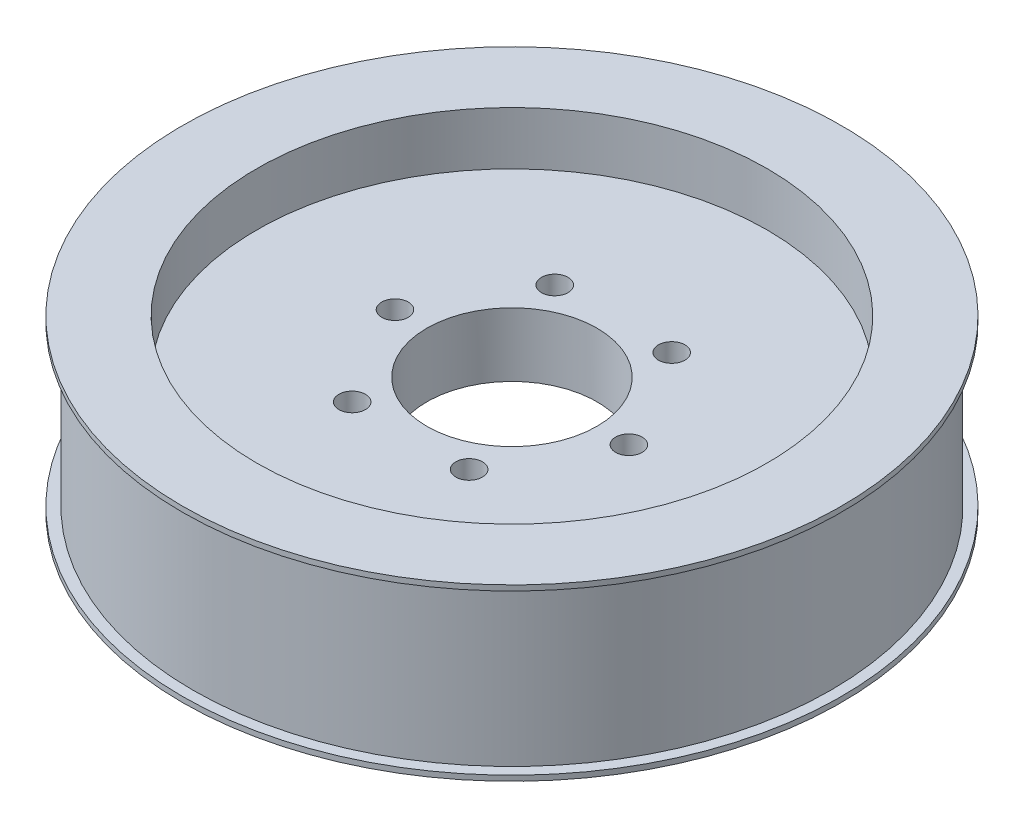
from build123d import *

# Parameters (mm, degrees)
SKETCH2_R          = 8
SKETCH2_R_2        = 1.25
CUT_EXTRUDE1_DEPTH = 15


with BuildPart() as part:
    # Sketch1 → Revolve1 (revolve)
    with BuildSketch(Plane.XY):
        Polygon((0, 10.150862069), (24, 10.150862069), (24, 15.150862069), (31, 15.150862069), (31, 14.650862069), (30, 14.650862069), (30, -0.349137931), (31, -0.349137931), (31, -0.849137931), (24, -0.849137931), (24, 4.150862069), (0, 4.150862069), align=None)
    revolve(axis=Axis((0, 36.012931034, 0), (0, -1, 0)))

    # Sketch2 → Cut-Extrude1 (cut, symmetric)
    with BuildSketch(Plane(origin=(0, 10.150862069, 0), x_dir=(1, 0, 0), z_dir=(0, 1, 0))):
        Circle(SKETCH2_R)
        with Locations((11, 0)):
            Circle(SKETCH2_R_2)
        with Locations((5.5, -9.526279442)):
            Circle(SKETCH2_R_2)
        with Locations((-5.5, -9.526279442)):
            Circle(SKETCH2_R_2)
        with Locations((-11, 0)):
            Circle(SKETCH2_R_2)
        with Locations((-5.5, 9.526279442)):
            Circle(SKETCH2_R_2)
        with Locations((5.5, 9.526279442)):
            Circle(SKETCH2_R_2)
    extrude(amount=CUT_EXTRUDE1_DEPTH, both=True, mode=Mode.SUBTRACT)


solid = part.part
